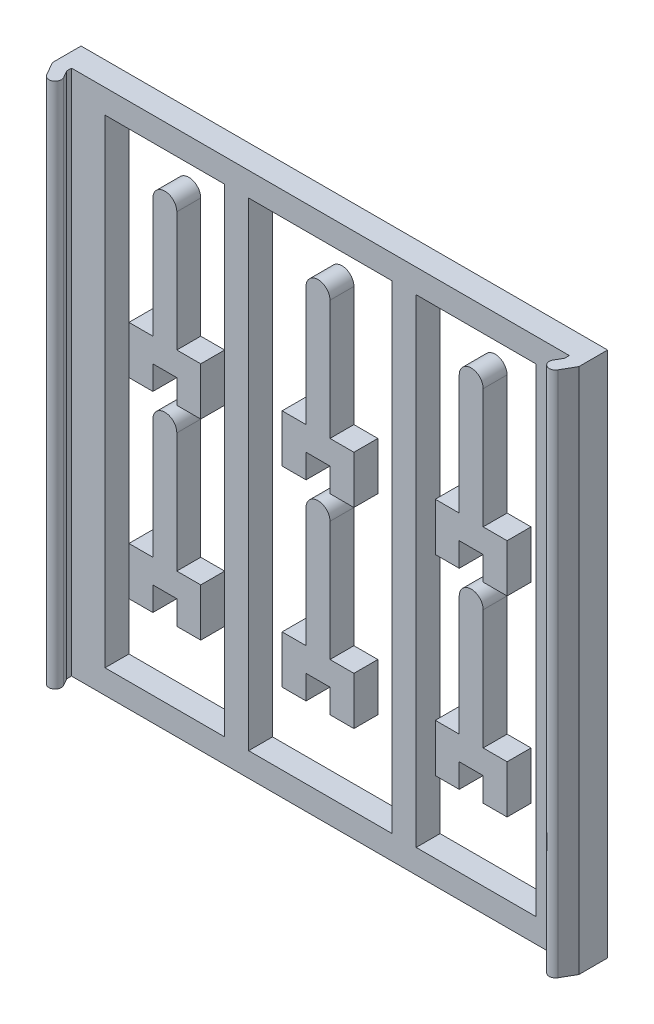
from build123d import *

# Parameters (mm, degrees)
SKETCH1_W             = 110
SKETCH1_H             = 110
SKETCH1_W_2           = 25
SKETCH1_H_2           = 100
SKETCH1_W_3           = 30
BOSS_EXTRUDE1_DEPTH   = 5
BOSS_EXTRUDE2_DEPTH   = 110
BOSS_EXTRUDE3_DEPTH   = 5
BOSS_EXTRUDE3_2_DEPTH = 5
BOSS_EXTRUDE3_3_DEPTH = 5
BOSS_EXTRUDE3_4_DEPTH = 5
BOSS_EXTRUDE3_5_DEPTH = 5
BOSS_EXTRUDE3_6_DEPTH = 5


with BuildPart() as part:
    # Sketch1 → Boss-Extrude1 (new body)
    with BuildSketch(Plane.XY):
        with Locations((55, 55)):
            Rectangle(SKETCH1_W, SKETCH1_H)
        with Locations((22.5, 55)):
            Rectangle(SKETCH1_W_2, SKETCH1_H_2, mode=Mode.SUBTRACT)
        with Locations((87.5, 55)):
            Rectangle(SKETCH1_W_2, SKETCH1_H_2, mode=Mode.SUBTRACT)
        with Locations((55, 55)):
            Rectangle(SKETCH1_W_3, SKETCH1_H_2, mode=Mode.SUBTRACT)
    extrude(amount=BOSS_EXTRUDE1_DEPTH)

    # Sketch2 → Boss-Extrude2 (add)
    with BuildSketch(Plane.XZ):
        with BuildLine():
            Line((0, 5), (3, 5))
            Line((3, 5), (3, 6))
            Line((3, 6), (3.866025404, 7.5))
            ThreePointArc((3.866025404, 7.5), (3.390544457, 9.274519053), (1.616025404, 8.799038106))
            Line((1.616025404, 8.799038106), (0, 6))
            Line((0, 6), (0, 5))
        make_face()
        with BuildLine():
            Line((110, 6), (110, 5))
            Line((110, 5), (107, 5))
            Line((107, 5), (107, 6))
            Line((107, 6), (106.133974596, 7.5))
            ThreePointArc((106.133974596, 7.5), (106.609455543, 9.274519053), (108.383974596, 8.799038106))
            Line((108.383974596, 8.799038106), (110, 6))
        make_face()
    extrude(amount=-BOSS_EXTRUDE2_DEPTH)


with BuildPart() as body_2:
    # Sketch3 → Boss-Extrude3 (new body)
    with BuildSketch(Plane.XY):
        with BuildLine():
            Line((20, 95), (20, 70))
            Line((20, 70), (15, 70))
            Line((15, 70), (15, 60))
            Line((15, 60), (20, 60))
            Line((20, 60), (20, 65))
            Line((20, 65), (25, 65))
            Line((25, 65), (25, 60))
            Line((25, 60), (30, 60))
            Line((30, 60), (30, 70))
            Line((30, 70), (25, 70))
            Line((25, 70), (25, 95))
            ThreePointArc((25, 95), (22.5, 97.5), (20, 95))
        make_face()
    extrude(amount=BOSS_EXTRUDE3_DEPTH)


with BuildPart() as body_3:
    # Sketch3 → Boss-Extrude3 2 (new body)
    with BuildSketch(Plane.XY):
        with BuildLine():
            Line((52, 95), (52, 70))
            Line((52, 70), (47, 70))
            Line((47, 70), (47, 60))
            Line((47, 60), (52, 60))
            Line((52, 60), (52, 65))
            Line((52, 65), (57, 65))
            Line((57, 65), (57, 60))
            Line((57, 60), (62, 60))
            Line((62, 60), (62, 70))
            Line((62, 70), (57, 70))
            Line((57, 70), (57, 95))
            ThreePointArc((57, 95), (54.5, 97.5), (52, 95))
        make_face()
    extrude(amount=BOSS_EXTRUDE3_2_DEPTH)


with BuildPart() as body_4:
    # Sketch3 → Boss-Extrude3 3 (new body)
    with BuildSketch(Plane.XY):
        with BuildLine():
            Line((84, 95), (84, 70))
            Line((84, 70), (79, 70))
            Line((79, 70), (79, 60))
            Line((79, 60), (84, 60))
            Line((84, 60), (84, 65))
            Line((84, 65), (89, 65))
            Line((89, 65), (89, 60))
            Line((89, 60), (94, 60))
            Line((94, 60), (94, 70))
            Line((94, 70), (89, 70))
            Line((89, 70), (89, 95))
            ThreePointArc((89, 95), (86.5, 97.5), (84, 95))
        make_face()
    extrude(amount=BOSS_EXTRUDE3_3_DEPTH)


with BuildPart() as body_5:
    # Sketch3 → Boss-Extrude3 4 (new body)
    with BuildSketch(Plane.XY):
        with BuildLine():
            Line((52, 55), (52, 30))
            Line((52, 30), (47, 30))
            Line((47, 30), (47, 20))
            Line((47, 20), (52, 20))
            Line((52, 20), (52, 25))
            Line((52, 25), (57, 25))
            Line((57, 25), (57, 20))
            Line((57, 20), (62, 20))
            Line((62, 20), (62, 30))
            Line((62, 30), (57, 30))
            Line((57, 30), (57, 55))
            ThreePointArc((57, 55), (54.5, 57.5), (52, 55))
        make_face()
    extrude(amount=BOSS_EXTRUDE3_4_DEPTH)


with BuildPart() as body_6:
    # Sketch3 → Boss-Extrude3 5 (new body)
    with BuildSketch(Plane.XY):
        with BuildLine():
            Line((84, 55), (84, 30))
            Line((84, 30), (79, 30))
            Line((79, 30), (79, 20))
            Line((79, 20), (84, 20))
            Line((84, 20), (84, 25))
            Line((84, 25), (89, 25))
            Line((89, 25), (89, 20))
            Line((89, 20), (94, 20))
            Line((94, 20), (94, 30))
            Line((94, 30), (89, 30))
            Line((89, 30), (89, 55))
            ThreePointArc((89, 55), (86.5, 57.5), (84, 55))
        make_face()
    extrude(amount=BOSS_EXTRUDE3_5_DEPTH)


with BuildPart() as body_7:
    # Sketch3 → Boss-Extrude3 6 (new body)
    with BuildSketch(Plane.XY):
        with BuildLine():
            Line((20, 55), (20, 30))
            Line((20, 30), (15, 30))
            Line((15, 30), (15, 20))
            Line((15, 20), (20, 20))
            Line((20, 20), (20, 25))
            Line((20, 25), (25, 25))
            Line((25, 25), (25, 20))
            Line((25, 20), (30, 20))
            Line((30, 20), (30, 30))
            Line((30, 30), (25, 30))
            Line((25, 30), (25, 55))
            ThreePointArc((25, 55), (22.5, 57.5), (20, 55))
        make_face()
    extrude(amount=BOSS_EXTRUDE3_6_DEPTH)


solid = Compound([part.part, body_2.part, body_3.part, body_4.part, body_5.part, body_6.part, body_7.part])
